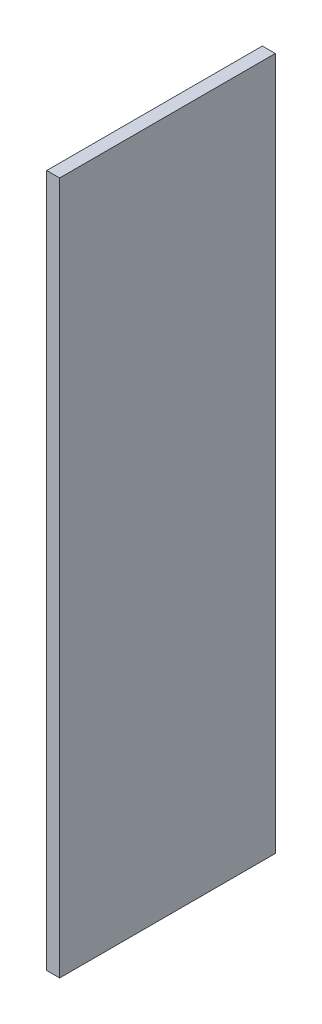
from build123d import *

# Parameters (mm, degrees)
SKETCH1_W           = 300
SKETCH1_H           = 964
BOSS_EXTRUDE1_DEPTH = 18


with BuildPart() as part:
    # Sketch1 → Boss-Extrude1 (new body)
    with BuildSketch(Plane(origin=(0, 0, 0), x_dir=(0, 0, -1), z_dir=(1, 0, 0))):
        with Locations((-117.607933189, -424.219556499)):
            Rectangle(SKETCH1_W, SKETCH1_H)
    extrude(amount=BOSS_EXTRUDE1_DEPTH)


solid = part.part
